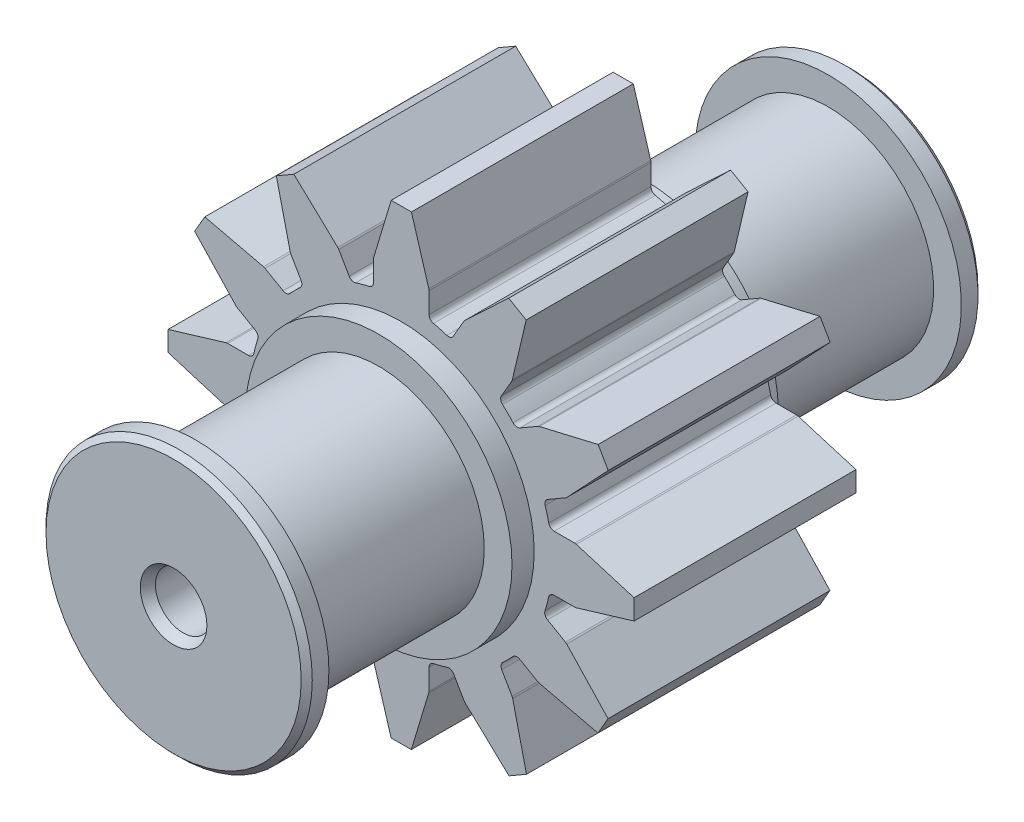
from build123d import *

# Parameters (mm, degrees)
EXTRUDE_1_DEPTH      = 20
SKETCH_3_R           = 12
EXTRUDE_2_DEPTH      = 2
SKETCH_4_R           = 12
EXTRUDE_3_DEPTH      = 2
SKETCH_5_R           = 9.5
EXTRUDE_4_DEPTH      = 16.5
SKETCH_6_R           = 12
EXTRUDE_5_DEPTH      = 2
CHAMFER_2_SIZE       = 0.5
SKETCH_7_R           = 9.5
EXTRUDE_6_DEPTH      = 16.5
SKETCH_8_R           = 12
EXTRUDE_7_DEPTH      = 2
CHAMFER_3_SIZE       = 0.5
SKETCH_15_R          = 2.5
CUT_EXTRUDE_13_DEPTH = 74
CHAMFER_6_SIZE       = 0.5
CHAMFER_6_SIZE2      = 0.866025404
CHAMFER_9_SIZE       = 0.5
CHAMFER_9_SIZE2      = 0.866025404


with BuildPart() as part:
    # Эскиз2 → Вытянуть1 (new body)
    with BuildSketch(Plane.XY):
        with BuildLine():
            Line((53.764538287, -2.946020686), (53.764538287, -1.077143616))
            ThreePointArc((53.764538287, -1.077143616), (53.759197394, -1.004257629), (53.743288818, -0.932928746))
            Line((53.743288818, -0.932928746), (52.174732421, 4.274212553))
            Line((52.174732421, 4.274212553), (50.354570926, 4.274212553))
            Line((50.354570926, 4.274212553), (48.785793437, -0.932919949))
            ThreePointArc((48.785793437, -0.932919949), (48.769880615, -1.004257948), (48.764538287, -1.077153679))
            Line((48.764538287, -1.077153679), (48.764538287, -2.953138509))
            ThreePointArc((48.764538287, -2.953138509), (48.653798767, -3.266947811), (48.370633173, -3.441752748))
            ThreePointArc((48.370633173, -3.441752748), (47.755574297, -3.590379289), (47.148101498, -3.767478327))
            ThreePointArc((47.148101498, -3.767478327), (46.816157953, -3.756991645), (46.564008916, -3.540849677))
            Line((46.564008916, -3.540849677), (45.628704767, -1.920855369))
            ThreePointArc((45.628704767, -1.920855369), (45.587636424, -1.860404698), (45.538194752, -1.806586362))
            Line((45.538194752, -1.806586362), (41.576214415, 1.918652085))
            Line((41.576214415, 1.918652085), (39.999908322, 1.008571338))
            Line((39.999908322, 1.008571338), (41.244873414, -4.285326434))
            ThreePointArc((41.244873414, -4.285326434), (41.266761505, -4.355063364), (41.298582779, -4.420864083))
            Line((41.298582779, -4.420864083), (42.233043669, -6.039397823))
            ThreePointArc((42.233043669, -6.039397823), (42.29400173, -6.366811555), (42.135803463, -6.659879713))
            ThreePointArc((42.135803463, -6.659879713), (41.671118276, -7.10145189), (41.227792451, -7.564464333))
            ThreePointArc((41.227792451, -7.564464333), (40.935062472, -7.721409797), (40.608582641, -7.660306282))
            Line((40.608582641, -7.660306282), (38.980519219, -6.720343428))
            ThreePointArc((38.980519219, -6.720343428), (38.914727656, -6.688525782), (38.845000744, -6.666638572))
            Line((38.845000744, -6.666638572), (33.551205899, -5.42147761))
            Line((33.551205899, -5.42147761), (32.641125152, -6.997783703))
            Line((32.641125152, -6.997783703), (36.36624071, -10.959946087))
            ThreePointArc((36.36624071, -10.959946087), (36.42007011, -11.009400187), (36.480534902, -11.050477203))
            Line((36.480534902, -11.050477203), (38.099195221, -11.984952893))
            ThreePointArc((38.099195221, -11.984952893), (38.3156739, -12.237948594), (38.325284093, -12.570781115))
            ThreePointArc((38.325284093, -12.570781115), (38.135802793, -13.215524272), (37.978453065, -13.868852647))
            ThreePointArc((37.978453065, -13.868852647), (37.803845806, -14.152755097), (37.48960436, -14.263843393))
            Line((37.48960436, -14.263843393), (35.609921104, -14.263843393))
            ThreePointArc((35.609921104, -14.263843393), (35.536992217, -14.269190608), (35.465623196, -14.285117883))
            Line((35.465623196, -14.285117883), (30.241497591, -15.859778889))
            Line((30.241497591, -15.859778889), (30.258564934, -17.673810753))
            Line((30.258564934, -17.673810753), (35.465697436, -19.242588243))
            ThreePointArc((35.465697436, -19.242588243), (35.537035435, -19.258501065), (35.609931166, -19.263843393))
            Line((35.609931166, -19.263843393), (37.515142589, -19.263843393))
            ThreePointArc((37.515142589, -19.263843393), (37.828138332, -19.373928448), (38.003309462, -19.655708734))
            ThreePointArc((38.003309462, -19.655708734), (38.149518751, -20.25162588), (38.322513601, -20.840325449))
            ThreePointArc((38.322513601, -20.840325449), (38.312380747, -21.172625221), (38.09610656, -21.425115396))
            Line((38.09610656, -21.425115396), (36.477531273, -22.359600274))
            ThreePointArc((36.477531273, -22.359600274), (36.417080602, -22.400668616), (36.363262266, -22.450110289))
            Line((36.363262266, -22.450110289), (32.638023819, -26.412090625))
            Line((32.638023819, -26.412090625), (33.548104566, -27.988396718))
            Line((33.548104566, -27.988396718), (38.837821827, -26.744414757))
            ThreePointArc((38.837821827, -26.744414757), (38.911454943, -26.720963772), (38.980594997, -26.686446567))
            Line((38.980594997, -26.686446567), (40.557311134, -25.740478688))
            ThreePointArc((40.557311134, -25.740478688), (40.887974912, -25.674653662), (41.185251899, -25.833706677))
            ThreePointArc((41.185251899, -25.833706677), (41.655272975, -26.327509287), (42.149482788, -26.797102185))
            ThreePointArc((42.149482788, -26.797102185), (42.308189645, -27.09030597), (42.247291035, -27.418098106))
            Line((42.247291035, -27.418098106), (41.313149687, -29.036078382))
            ThreePointArc((41.313149687, -29.036078382), (41.281332042, -29.101869945), (41.259444832, -29.171596858))
            Line((41.259444832, -29.171596858), (40.014283869, -34.465391703))
            Line((40.014283869, -34.465391703), (41.590589962, -35.37547245))
            Line((41.590589962, -35.37547245), (45.552970023, -31.650152239))
            ThreePointArc((45.552970023, -31.650152239), (45.602242473, -31.596552031), (45.643208409, -31.536364418))
            Line((45.643208409, -31.536364418), (46.589687492, -29.901332509))
            ThreePointArc((46.589687492, -29.901332509), (46.841408349, -29.685740418), (47.172658361, -29.674934436))
            ThreePointArc((47.172658361, -29.674934436), (47.763729285, -29.846529298), (48.361967201, -29.991170333))
            ThreePointArc((48.361967201, -29.991170333), (48.644883646, -30.166041654), (48.75550534, -30.479704745))
            Line((48.75550534, -30.479704745), (48.75550534, -32.34734856))
            ThreePointArc((48.75550534, -32.34734856), (48.760846232, -32.420234547), (48.776754809, -32.49156343))
            Line((48.776754809, -32.49156343), (50.345311205, -37.698704729))
            Line((50.345311205, -37.698704729), (52.1654727, -37.698704729))
            Line((52.1654727, -37.698704729), (53.734250189, -32.491572227))
            ThreePointArc((53.734250189, -32.491572227), (53.750163012, -32.420234228), (53.75550534, -32.347338497))
            Line((53.75550534, -32.347338497), (53.75550534, -30.477514017))
            ThreePointArc((53.75550534, -30.477514017), (53.866087201, -30.163900379), (54.148919394, -29.989006661))
            ThreePointArc((54.148919394, -29.989006661), (54.776030579, -29.836482847), (55.395187259, -29.654337418))
            ThreePointArc((55.395187259, -29.654337418), (55.727840657, -29.664117847), (55.980669977, -29.880523195))
            Line((55.980669977, -29.880523195), (56.918293093, -31.50453407))
            ThreePointArc((56.918293093, -31.50453407), (56.959361435, -31.564984741), (57.008803108, -31.618803077))
            Line((57.008803108, -31.618803077), (60.970783444, -35.344041525))
            Line((60.970783444, -35.344041525), (62.547089537, -34.433960777))
            Line((62.547089537, -34.433960777), (61.302124446, -29.140063005))
            ThreePointArc((61.302124446, -29.140063005), (61.280236354, -29.070326075), (61.248415081, -29.004525356))
            Line((61.248415081, -29.004525356), (60.313352567, -27.384949575))
            ThreePointArc((60.313352567, -27.384949575), (60.252285616, -27.058233892), (60.409547147, -26.765418044))
            ThreePointArc((60.409547147, -26.765418044), (60.874734414, -26.320800568), (61.318355435, -25.854662946))
            ThreePointArc((61.318355435, -25.854662946), (61.611362594, -25.69669226), (61.938606865, -25.757676849))
            Line((61.938606865, -25.757676849), (63.556770089, -26.691923822))
            ThreePointArc((63.556770089, -26.691923822), (63.622561652, -26.723741467), (63.692288565, -26.745628677))
            Line((63.692288565, -26.745628677), (68.986083409, -27.990789639))
            Line((68.986083409, -27.990789639), (69.896164156, -26.414483546))
            Line((69.896164156, -26.414483546), (66.171043874, -22.452316137))
            ThreePointArc((66.171043874, -22.452316137), (66.117219766, -22.402866229), (66.056761375, -22.361791772))
            Line((66.056761375, -22.361791772), (64.43714748, -21.426707253))
            ThreePointArc((64.43714748, -21.426707253), (64.220913014, -21.174319639), (64.210673714, -20.84212691))
            ThreePointArc((64.210673714, -20.84212691), (64.390016693, -20.228801746), (64.540344527, -19.607727513))
            ThreePointArc((64.540344527, -19.607727513), (64.715163733, -19.324615398), (65.028941656, -19.213901173))
            Line((65.028941656, -19.213901173), (66.888769323, -19.213901173))
            ThreePointArc((66.888769323, -19.213901173), (66.961655311, -19.208560281), (67.032984194, -19.192651704))
            Line((67.032984194, -19.192651704), (72.240125492, -17.624095307))
            Line((72.240125492, -17.624095307), (72.240125492, -15.803933813))
            Line((72.240125492, -15.803933813), (67.033013036, -14.235162363))
            ThreePointArc((67.033013036, -14.235162363), (66.961654766, -14.219246553), (66.888738326, -14.213907214))
            Line((66.888738326, -14.213907214), (65.038418761, -14.214058869))
            ThreePointArc((65.038418761, -14.214058869), (64.724765213, -14.103477871), (64.549862276, -13.820607462))
            ThreePointArc((64.549862276, -13.820607462), (64.40200748, -13.210628208), (64.226184375, -12.608115166))
            ThreePointArc((64.226184375, -12.608115166), (64.236662079, -12.276162568), (64.452807408, -12.024004868))
            Line((64.452807408, -12.024004868), (66.072795877, -11.088704089))
            ThreePointArc((66.072795877, -11.088704089), (66.133246547, -11.047635747), (66.187064884, -10.998194074))
            Line((66.187064884, -10.998194074), (69.912303331, -7.036213738))
            Line((69.912303331, -7.036213738), (69.002222584, -5.459907645))
            Line((69.002222584, -5.459907645), (63.708324812, -6.704872737))
            ThreePointArc((63.708324812, -6.704872737), (63.638587881, -6.726760828), (63.572787163, -6.758582102))
            Line((63.572787163, -6.758582102), (61.954455243, -7.692926471))
            ThreePointArc((61.954455243, -7.692926471), (61.626900937, -7.75386248), (61.3337823, -7.595475342))
            ThreePointArc((61.3337823, -7.595475342), (60.870851004, -7.108824873), (60.384451797, -6.645629585))
            ThreePointArc((60.384451797, -6.645629585), (60.226244716, -6.352559068), (60.287201748, -6.025138774))
            Line((60.287201748, -6.025138774), (61.21857227, -4.41195771))
            ThreePointArc((61.21857227, -4.41195771), (61.250389916, -4.346166146), (61.272277126, -4.276439234))
            Line((61.272277126, -4.276439234), (62.517438088, 1.017355611))
            Line((62.517438088, 1.017355611), (60.941131995, 1.927436358))
            Line((60.941131995, 1.927436358), (56.978964585, -1.797683924))
            ThreePointArc((56.978964585, -1.797683924), (56.929514677, -1.851508033), (56.88844022, -1.911966424))
            Line((56.88844022, -1.911966424), (55.953232083, -3.531794433))
            ThreePointArc((55.953232083, -3.531794433), (55.70097994, -3.747976393), (55.368928673, -3.758356204))
            ThreePointArc((55.368928673, -3.758356204), (54.767086452, -3.582459006), (54.157776241, -3.434489586))
            ThreePointArc((54.157776241, -3.434489586), (53.875063626, -3.259564126), (53.764538287, -2.946020686))
        make_face()
    extrude(amount=EXTRUDE_1_DEPTH)

    # Эскиз3 → Вытянуть2 (add)
    with BuildSketch(Plane(origin=(0, 0, 0), x_dir=(-1, 0, 0), z_dir=(0, 0, -1))):
        with Locations((-51.240125492, -16.733104028)):
            Circle(SKETCH_3_R)
    extrude(amount=EXTRUDE_2_DEPTH)

    # Эскиз4 → Вытянуть3 (add)
    with BuildSketch(Plane.XY.offset(20)):
        with Locations((51.240125492, -16.733104028)):
            Circle(SKETCH_4_R)
    extrude(amount=EXTRUDE_3_DEPTH)

    # Эскиз5 → Вытянуть4 (add)
    with BuildSketch(Plane(origin=(0, 0, -2), x_dir=(-1, 0, 0), z_dir=(0, 0, -1))):
        with Locations((-51.240125492, -16.733104028)):
            Circle(SKETCH_5_R)
    extrude(amount=EXTRUDE_4_DEPTH)

    # Эскиз6 → Вытянуть5 (add)
    with BuildSketch(Plane(origin=(0, 0, -18.5), x_dir=(-1, 0, 0), z_dir=(0, 0, -1))):
        with Locations((-51.240125492, -16.733104028)):
            Circle(SKETCH_6_R)
    extrude(amount=EXTRUDE_5_DEPTH)

    # Фаска2
    chamfer_2_edges = [part.edges().sort_by_distance(p)[0] for p in [
        (63.240125492, -16.733104028, -20.5),
    ]]
    chamfer(chamfer_2_edges, length=CHAMFER_2_SIZE)

    # Эскиз7 → Вытянуть6 (add)
    with BuildSketch(Plane.XY.offset(22)):
        with Locations((51.240125492, -16.733104028)):
            Circle(SKETCH_7_R)
    extrude(amount=EXTRUDE_6_DEPTH)

    # Эскиз8 → Вытянуть7 (add)
    with BuildSketch(Plane.XY.offset(38.5)):
        with Locations((51.240125492, -16.733104028)):
            Circle(SKETCH_8_R)
    extrude(amount=EXTRUDE_7_DEPTH)

    # Фаска3
    chamfer_3_edges = [part.edges().sort_by_distance(p)[0] for p in [
        (39.240125492, -16.733104028, 40.5),
    ]]
    chamfer(chamfer_3_edges, length=CHAMFER_3_SIZE)

    # Эскиз15 → Вытянуть13 (cut)
    with BuildSketch(Plane(origin=(0, 0, -20.5), x_dir=(-1, 0, 0), z_dir=(0, 0, -1))):
        with Locations((-51.240125492, -16.733104028)):
            Circle(SKETCH_15_R)
    extrude(amount=-CUT_EXTRUDE_13_DEPTH, mode=Mode.SUBTRACT)

    # Фаска6
    chamfer_6_edges = [part.edges().sort_by_distance(p)[0] for p in [
        (53.740125492, -16.733104028, -20.5),
    ]]
    chamfer_6_side = [part.faces().sort_by_distance(p)[0] for p in [
        (62.414856373, -16.733104028, -20.5),
    ]]
    chamfer(chamfer_6_edges, length=CHAMFER_6_SIZE, length2=CHAMFER_6_SIZE2, reference=chamfer_6_side[0])

    # Фаска9
    chamfer_9_edges = [part.edges().sort_by_distance(p)[0] for p in [
        (53.740125492, -16.733104028, 40.5),
    ]]
    chamfer_9_side = [part.faces().sort_by_distance(p)[0] for p in [
        (40.065394612, -16.733104028, 40.5),
    ]]
    chamfer(chamfer_9_edges, length=CHAMFER_9_SIZE, length2=CHAMFER_9_SIZE2, reference=chamfer_9_side[0])


solid = part.part
